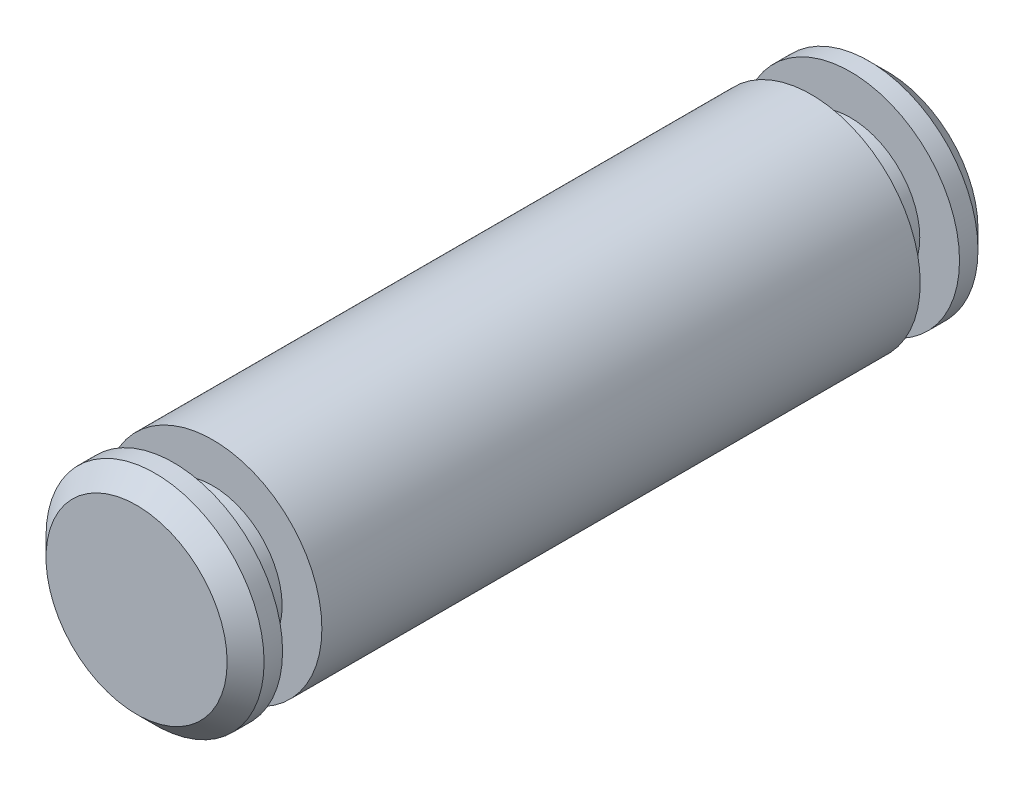
from build123d import *

# Parameters (mm, degrees)
SKETCH1_R           = 1.4986
BOSS_EXTRUDE1_DEPTH = 5.159375
SKETCH2_W           = 0.54
SKETCH2_H           = 0.5461
CHAMFER1_SIZE       = 0.254


with BuildPart() as part:
    # Sketch1 → Boss-Extrude1 (new body, symmetric)
    with BuildSketch(Plane.XY):
        Circle(SKETCH1_R)
    extrude(amount=BOSS_EXTRUDE1_DEPTH, both=True)

    # Sketch2 → Cut-Revolve1 (revolve, cut)
    with BuildSketch(Plane(origin=(0, 0, 0), x_dir=(0, 0, -1), z_dir=(1, 0, 0))):
        with Locations((-4.381375, -1.22555)):
            Rectangle(SKETCH2_W, SKETCH2_H)
        with Locations((4.381375, -1.22555)):
            Rectangle(SKETCH2_W, SKETCH2_H)
    revolve(axis=Axis((0, 0, 8.828032455), (0, 0, -1)), mode=Mode.SUBTRACT)

    # Chamfer1
    chamfer1_edges = [part.edges().sort_by_distance(p)[0] for p in [
        (-1.4986, 0, -5.159375),
        (-1.4986, 0, 5.159375),
    ]]
    chamfer(chamfer1_edges, length=CHAMFER1_SIZE)


solid = part.part
